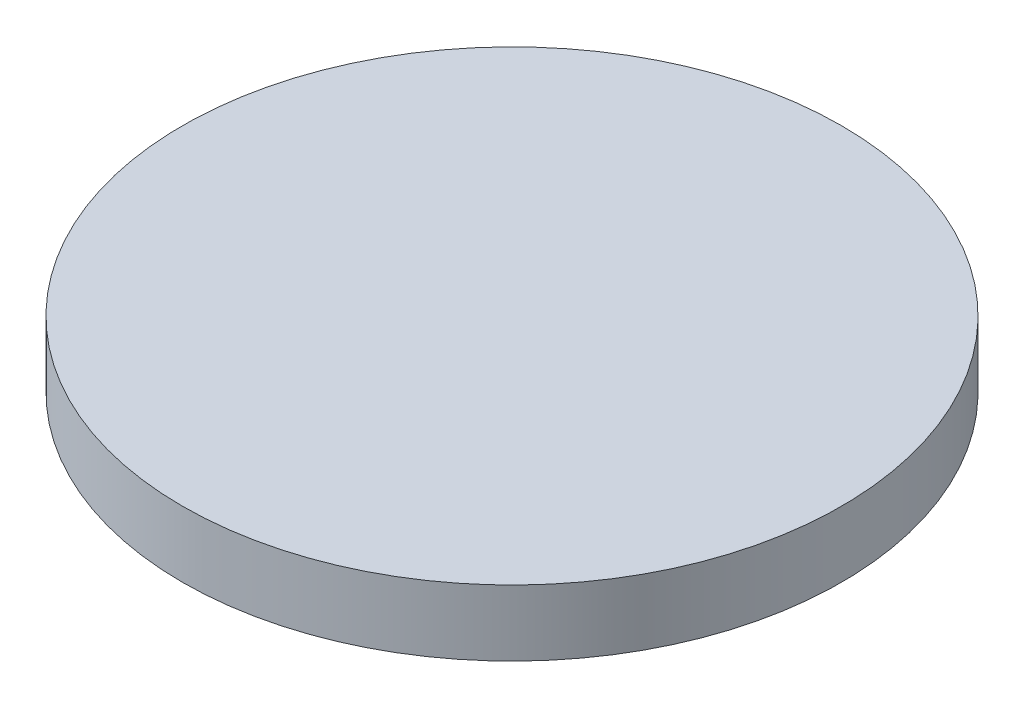
from build123d import *

# Parameters (mm, degrees)
ESQUISSE1_R        = 15
BOSS_EXTRU_1_DEPTH = 3


with BuildPart() as part:
    # Esquisse1 → Boss.-Extru.1 (new body)
    with BuildSketch(Plane(origin=(0, 0, 0), x_dir=(1, 0, 0), z_dir=(0, 1, 0))):
        Circle(ESQUISSE1_R)
    extrude(amount=BOSS_EXTRU_1_DEPTH)


solid = part.part
